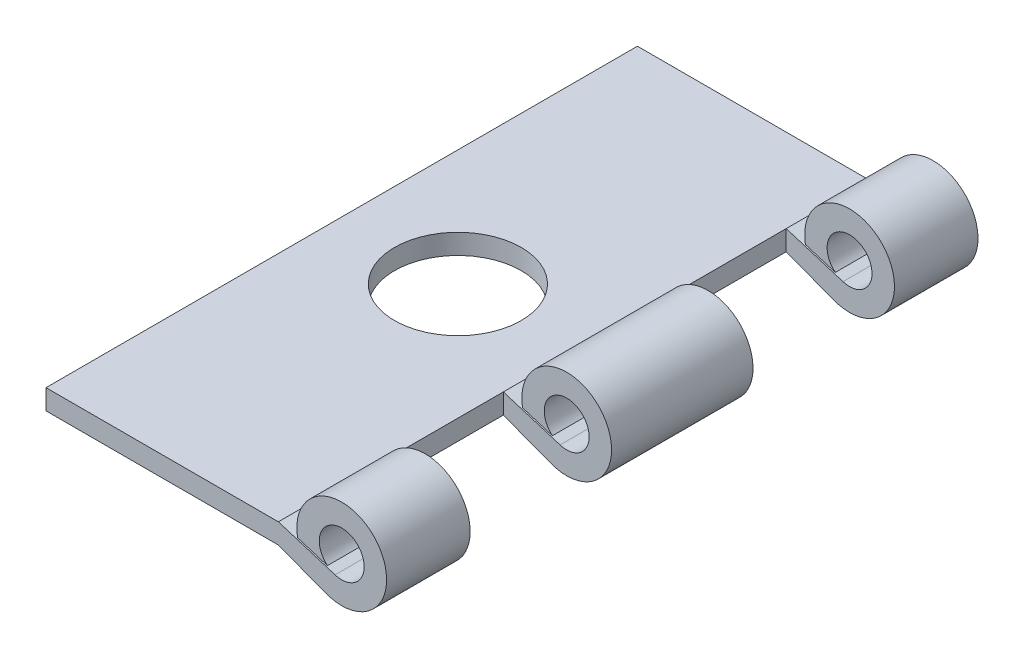
from build123d import *

# Parameters (mm, degrees)
BOSS_EXTRUDE1_DEPTH = 88.9
SKETCH2_W           = 16.271875
SKETCH2_H           = 21.2598
CUT_EXTRUDE1_DEPTH  = 44.45
SKETCH3_R           = 9.525
CUT_EXTRUDE2_DEPTH  = 88.9


with BuildPart() as part:
    # Sketch1 → Boss-Extrude1 (new body)
    with BuildSketch(Plane.XY):
        with BuildLine():
            Line((9.3265625, -3.6068), (16.461695383, -6.309426078))
            ThreePointArc((16.461695383, -6.309426078), (24.035016902, 4.318810338), (12.214407069, -1.21181271))
            Line((12.214407069, -1.21181271), (16.702709255, -2.600482704))
            ThreePointArc((16.702709255, -2.600482704), (20.455010949, 2.968001624), (17.854463061, -3.222712099))
            Line((17.854463061, -3.222712099), (9.3265625, -0.5842))
            Line((9.3265625, -0.5842), (-25.5984375, -0.5842))
            Line((-25.5984375, -0.5842), (-25.5984375, -3.6068))
            Line((-25.5984375, -3.6068), (9.3265625, -3.6068))
        make_face()
    extrude(amount=BOSS_EXTRUDE1_DEPTH)

    # Sketch2 → Cut-Extrude1 (cut, symmetric)
    with BuildSketch(Plane(origin=(0, -0.5842, 0), x_dir=(1, 0, 0), z_dir=(0, 1, 0))):
        with Locations((17.4625, -65.7098)):
            Rectangle(SKETCH2_W, SKETCH2_H)
        with Locations((17.4625, -23.1902)):
            Rectangle(SKETCH2_W, SKETCH2_H)
    extrude(amount=CUT_EXTRUDE1_DEPTH, both=True, mode=Mode.SUBTRACT)

    # Sketch3 → Cut-Extrude2 (cut)
    with BuildSketch(Plane.XZ.offset(3.6068)):
        with Locations((-8.1359375, 44.45)):
            Circle(SKETCH3_R)
    extrude(amount=-CUT_EXTRUDE2_DEPTH, mode=Mode.SUBTRACT)


solid = part.part
